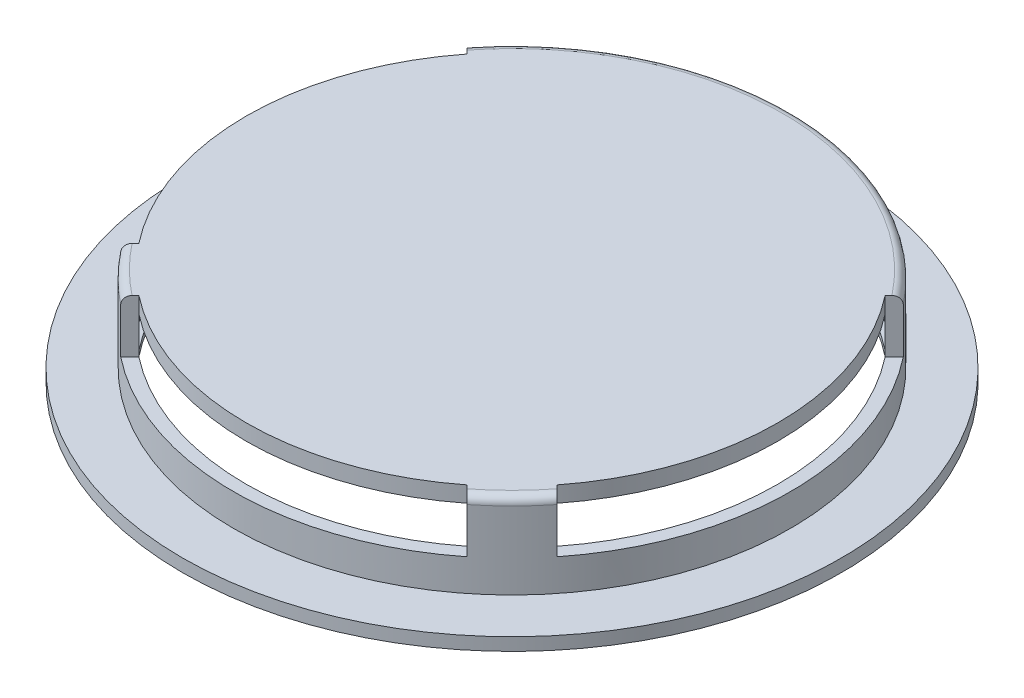
from build123d import *

# Parameters (mm, degrees)
SKETCH1_R           = 31
SKETCH1_R_2         = 25
BOSS_EXTRUDE1_DEPTH = 1.2
SKETCH2_R           = 26.2
SKETCH2_R_2         = 25
BOSS_EXTRUDE2_DEPTH = 6.5
SKETCH3_R           = 26.2
BOSS_EXTRUDE3_DEPTH = 1.5
CUT_EXTRUDE2_DEPTH  = 5
CUT_EXTRUDE3_START  = -0.5
SKETCH7_R           = 25.6
SKETCH7_R_2         = 25
CUT_EXTRUDE3_DEPTH  = 3
FILLET1_R           = 0.75
SKETCH8_R           = 3.5
SKETCH8_R_2         = 2
BOSS_EXTRUDE4_DEPTH = 3.5


with BuildPart() as part:
    # Sketch1 → Boss-Extrude1 (new body)
    with BuildSketch(Plane(origin=(0, 0, 0), x_dir=(1, 0, 0), z_dir=(0, 1, 0))):
        Circle(SKETCH1_R)
        Circle(SKETCH1_R_2, mode=Mode.SUBTRACT)
    extrude(amount=BOSS_EXTRUDE1_DEPTH)

    # Sketch2 → Boss-Extrude2 (add)
    with BuildSketch(Plane(origin=(0, 1.2, 0), x_dir=(1, 0, 0), z_dir=(0, 1, 0))):
        Circle(SKETCH2_R)
        Circle(SKETCH2_R_2, mode=Mode.SUBTRACT)
    extrude(amount=BOSS_EXTRUDE2_DEPTH)

    # Sketch3 → Boss-Extrude3 (add)
    with BuildSketch(Plane(origin=(0, 7.7, 0), x_dir=(1, 0, 0), z_dir=(0, 1, 0))):
        Circle(SKETCH3_R)
    extrude(amount=BOSS_EXTRUDE3_DEPTH)

    # Sketch5 → Cut-Extrude2 (cut)
    with BuildSketch(Plane(origin=(0, 9.2, 0), x_dir=(1, 0, 0), z_dir=(0, 1, 0))):
        with BuildLine():
            Line((20.525667656, 16.283026969), (19.671249118, 15.428608431))
            ThreePointArc((19.671249118, 15.428608431), (25, 0), (19.671249118, -15.428608431))
            Line((19.671249118, -15.428608431), (20.525667656, -16.283026969))
            ThreePointArc((20.525667656, -16.283026969), (26.2, 0), (20.525667656, 16.283026969))
        make_face()
        with BuildLine():
            Line((16.283026969, -20.525667656), (15.428608431, -19.671249118))
            ThreePointArc((15.428608431, -19.671249118), (0, -25), (-15.428608431, -19.671249118))
            Line((-15.428608431, -19.671249118), (-16.283026969, -20.525667656))
            ThreePointArc((-16.283026969, -20.525667656), (0, -26.2), (16.283026969, -20.525667656))
        make_face()
        with BuildLine():
            Line((-19.671249118, -15.428608431), (-20.525667656, -16.283026969))
            ThreePointArc((-20.525667656, -16.283026969), (-26.2, 0), (-20.525667656, 16.283026969))
            Line((-20.525667656, 16.283026969), (-19.671249118, 15.428608431))
            ThreePointArc((-19.671249118, 15.428608431), (-25, 0), (-19.671249118, -15.428608431))
        make_face()
    extrude(amount=-CUT_EXTRUDE2_DEPTH, mode=Mode.SUBTRACT)

    # Sketch7 → Cut-Extrude3 (cut)
    with BuildSketch(Plane.XZ.offset(CUT_EXTRUDE3_START)):
        Circle(SKETCH7_R)
        Circle(SKETCH7_R_2, mode=Mode.SUBTRACT)
    extrude(amount=-CUT_EXTRUDE3_DEPTH, mode=Mode.SUBTRACT)

    # Fillet1
    fillet1_edges = [part.edges().sort_by_distance(p)[0] for p in [
        (18.526197667, 9.2, 18.526197667),
        (0, 9.2, -26.2),
        (-18.526197667, 9.2, 18.526197667),
    ]]
    fillet(fillet1_edges, radius=FILLET1_R)

    # Sketch8 → Boss-Extrude4 (add)
    with BuildSketch(Plane.XZ.offset(-7.7)):
        Circle(SKETCH8_R)
        Circle(SKETCH8_R_2, mode=Mode.SUBTRACT)
    extrude(amount=BOSS_EXTRUDE4_DEPTH)


solid = part.part
